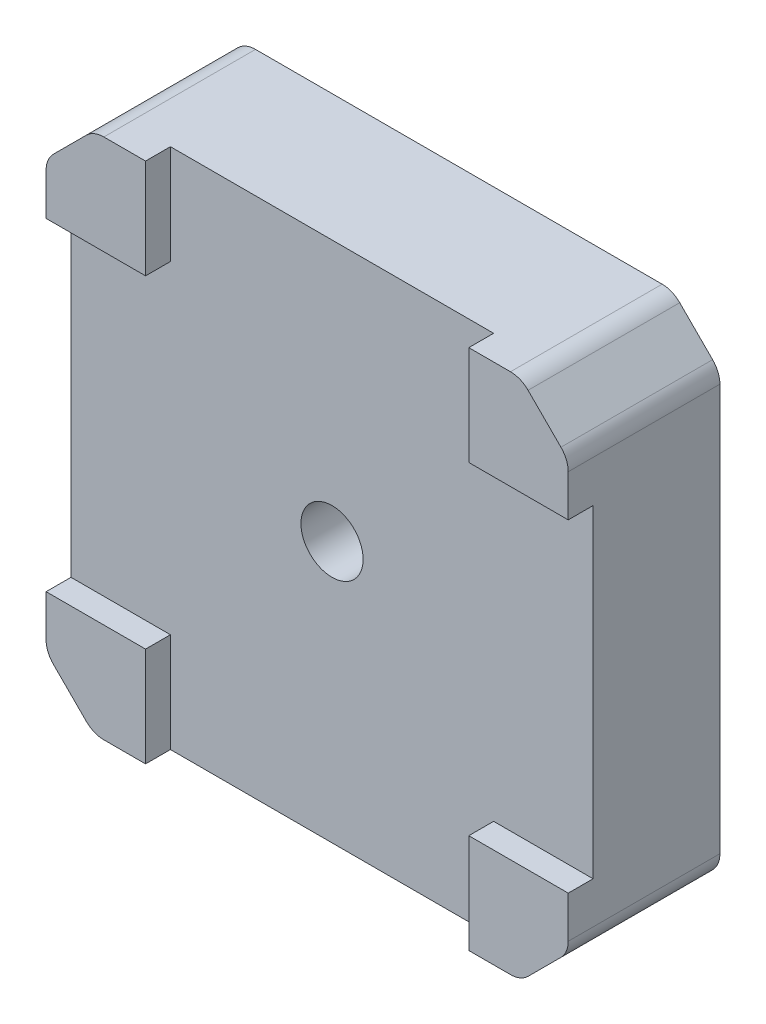
from build123d import *

# Parameters (mm, degrees)
BOSS_EXTRUDE1_DEPTH             = 12.2
SKETCH2_W                       = 2
SKETCH2_H                       = 26
CUT_EXTRUDE1_DEPTH              = 43
SKETCH3_W                       = 26
SKETCH3_H                       = 2
CUT_EXTRUDE2_DEPTH              = 43
SKETCH4_R                       = 16.5
CUT_EXTRUDE3_DEPTH              = 0.6
SKETCH5_R                       = 11
BOSS_EXTRUDE2_DEPTH             = 2.6
SKETCH6_R                       = 3.25
CUT_EXTRUDE4_DEPTH              = 2
SKETCH7_R                       = 2.5
CUT_EXTRUDE5_DEPTH              = 13.2
FILLET1_R                       = 0.5
FILLET3_R                       = 0.5
FILLET4_R                       = 2
M3X0_5_TAPPED_HOLE1_D           = 3
M3X0_5_TAPPED_HOLE1_DEPTH       = 10
M3X0_5_TAPPED_HOLE1_CSINK_D     = 3.5
M3X0_5_TAPPED_HOLE1_CSINK_ANGLE = 90
M3X0_5_TAPPED_HOLE1_TIP         = 0.901290929


with BuildPart() as part:
    # Sketch1 → Boss-Extrude1 (new body)
    with BuildSketch(Plane.XY):
        Polygon((-17.183766184, 21), (-21, 17.183766184), (-21, -17.183766184), (-17.183766184, -21), (17.183766184, -21), (21, -17.183766184), (21, 17.183766184), (17.183766184, 21), align=None)
    extrude(amount=BOSS_EXTRUDE1_DEPTH)

    # Sketch2 → Cut-Extrude1 (cut, through all)
    with BuildSketch(Plane(origin=(21, 0, 0), x_dir=(0, 0, -1), z_dir=(1, 0, 0))):
        with Locations((-11.2, 0)):
            Rectangle(SKETCH2_W, SKETCH2_H)
    extrude(amount=-CUT_EXTRUDE1_DEPTH, mode=Mode.SUBTRACT)

    # Sketch3 → Cut-Extrude2 (cut, through all)
    with BuildSketch(Plane(origin=(0, 21, 0), x_dir=(1, 0, 0), z_dir=(0, 1, 0))):
        with Locations((0, -11.2)):
            Rectangle(SKETCH3_W, SKETCH3_H)
    extrude(amount=-CUT_EXTRUDE2_DEPTH, mode=Mode.SUBTRACT)

    # Sketch4 → Cut-Extrude3 (cut)
    with BuildSketch(Plane(origin=(0, 0, 0), x_dir=(-1, 0, 0), z_dir=(0, 0, -1))):
        Circle(SKETCH4_R)
    extrude(amount=-CUT_EXTRUDE3_DEPTH, mode=Mode.SUBTRACT)

    # Sketch5 → Boss-Extrude2 (add)
    with BuildSketch(Plane(origin=(0, 0, 0.6), x_dir=(-1, 0, 0), z_dir=(0, 0, -1))):
        Circle(SKETCH5_R)
    extrude(amount=BOSS_EXTRUDE2_DEPTH)

    # Sketch6 → Cut-Extrude4 (cut)
    with BuildSketch(Plane(origin=(0, 0, -2), x_dir=(-1, 0, 0), z_dir=(0, 0, -1))):
        Circle(SKETCH6_R)
    extrude(amount=-CUT_EXTRUDE4_DEPTH, mode=Mode.SUBTRACT)

    # Sketch7 → Cut-Extrude5 (cut, through all)
    with BuildSketch(Plane(origin=(0, 0, 0), x_dir=(-1, 0, 0), z_dir=(0, 0, -1))):
        Circle(SKETCH7_R)
    extrude(amount=-CUT_EXTRUDE5_DEPTH, mode=Mode.SUBTRACT)

    # Fillet1
    fillet1_edges = [part.edges().sort_by_distance(p)[0] for p in [
        (3.25, 0, -2),
    ]]
    fillet(fillet1_edges, radius=FILLET1_R)

    # Fillet3
    fillet3_edges = [part.edges().sort_by_distance(p)[0] for p in [
        (11, 0, 0.6),
    ]]
    fillet(fillet3_edges, radius=FILLET3_R)

    # Fillet4
    fillet4_edges = [part.edges().sort_by_distance(p)[0] for p in [
        (17.183766184, 21, 6.1),
        (21, 17.183766184, 6.1),
        (21, -17.183766184, 6.1),
        (17.183766184, -21, 6.1),
        (-17.183766184, -21, 6.1),
        (-21, -17.183766184, 6.1),
        (-21, 17.183766184, 6.1),
        (-17.183766184, 21, 6.1),
    ]]
    fillet(fillet4_edges, radius=FILLET4_R)

    # M3x0.5 Tapped Hole1
    with Locations(Plane(origin=(0, 0, 0), x_dir=(-1, 0, 0), z_dir=(0, 0, -1))):
        with Locations((-15.5, -15.5), (-15.5, 15.5), (15.5, 15.5), (15.5, -15.5)):
            CounterSinkHole(M3X0_5_TAPPED_HOLE1_D / 2, M3X0_5_TAPPED_HOLE1_CSINK_D / 2, depth=M3X0_5_TAPPED_HOLE1_DEPTH, counter_sink_angle=M3X0_5_TAPPED_HOLE1_CSINK_ANGLE)
            with Locations((0, 0, -(M3X0_5_TAPPED_HOLE1_DEPTH + M3X0_5_TAPPED_HOLE1_TIP / 2))):  # 118° drill point
                Cone(0, M3X0_5_TAPPED_HOLE1_D / 2, M3X0_5_TAPPED_HOLE1_TIP, mode=Mode.SUBTRACT)


solid = part.part
